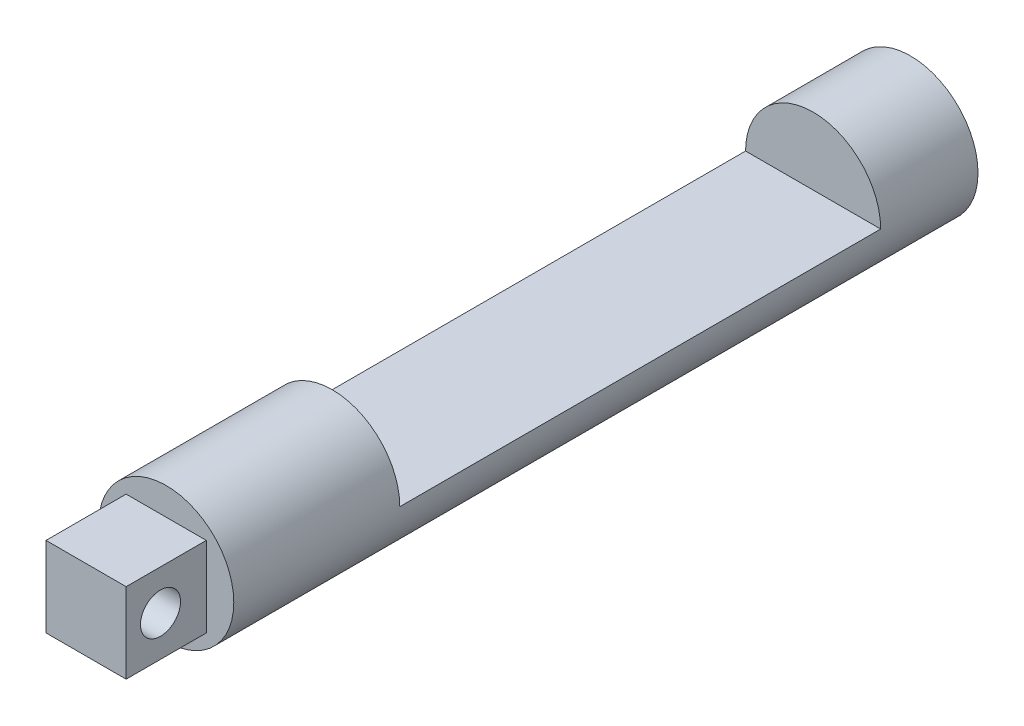
from build123d import *

# Parameters (mm, degrees)
CROQUIS1_R                   = 5.9
SALIENTE_EXTRUIR1_DEPTH      = 32.5
CORTAR_EXTRUIR1_DEPTH        = 24
CORTAR_EXTRUIR_L_MINA1_START = -6.5
CROQUIS3_R                   = 5.8
CROQUIS3_R_2                 = 5
CORTAR_EXTRUIR_L_MINA1_DEPTH = 3
CROQUIS4_W                   = 7
CROQUIS4_H                   = 7
SALIENTE_EXTRUIR2_DEPTH      = 7
CROQUIS6_R                   = 1.75
CORTAR_EXTRUIR3_DEPTH        = 42.029501581
CORTAR_EXTRUIR4_START        = 18
CORTAR_EXTRUIR4_DEPTH        = 18


with BuildPart() as part:
    # Croquis1 → Saliente-Extruir1 (new, symmetric)
    with BuildSketch(Plane.XY):
        Circle(CROQUIS1_R)
    extrude(amount=SALIENTE_EXTRUIR1_DEPTH, both=True)

    # Croquis2 → Cortar-Extruir1 (cut)
    with BuildSketch(Plane.XY):
        with BuildLine():
            Line((-5.9, 0), (5.9, 0))
            ThreePointArc((5.9, 0), (0, 5.9), (-5.9, 0))
        make_face()
    extrude(amount=-CORTAR_EXTRUIR1_DEPTH, mode=Mode.SUBTRACT)

    # Croquis3 → Cortar-Extruir-Lámina1 (cut)
    with BuildSketch(Plane.XY.offset(32.5).offset(CORTAR_EXTRUIR_L_MINA1_START)):
        Circle(CROQUIS3_R)
        Circle(CROQUIS3_R_2, mode=Mode.SUBTRACT)
    extrude(amount=-CORTAR_EXTRUIR_L_MINA1_DEPTH, mode=Mode.SUBTRACT)

    # Croquis4 → Saliente-Extruir2 (add)
    with BuildSketch(Plane.XY.offset(32.5)):
        Rectangle(CROQUIS4_W, CROQUIS4_H)
    extrude(amount=SALIENTE_EXTRUIR2_DEPTH)

    # Croquis6 → Cortar-Extruir3 (cut, through all)
    with BuildSketch(Plane.ZY.offset(3.5)):
        with Locations((36.5, 0)):
            Circle(CROQUIS6_R)
    extrude(amount=-CORTAR_EXTRUIR3_DEPTH, mode=Mode.SUBTRACT)

    # Croquis2_2 → Cortar-Extruir4 (cut)
    with BuildSketch(Plane.XY.offset(CORTAR_EXTRUIR4_START)):
        with BuildLine():
            Line((-5.9, 0), (5.9, 0))
            ThreePointArc((5.9, 0), (0, 5.9), (-5.9, 0))
        make_face()
    extrude(amount=-CORTAR_EXTRUIR4_DEPTH, mode=Mode.SUBTRACT)


solid = part.part
